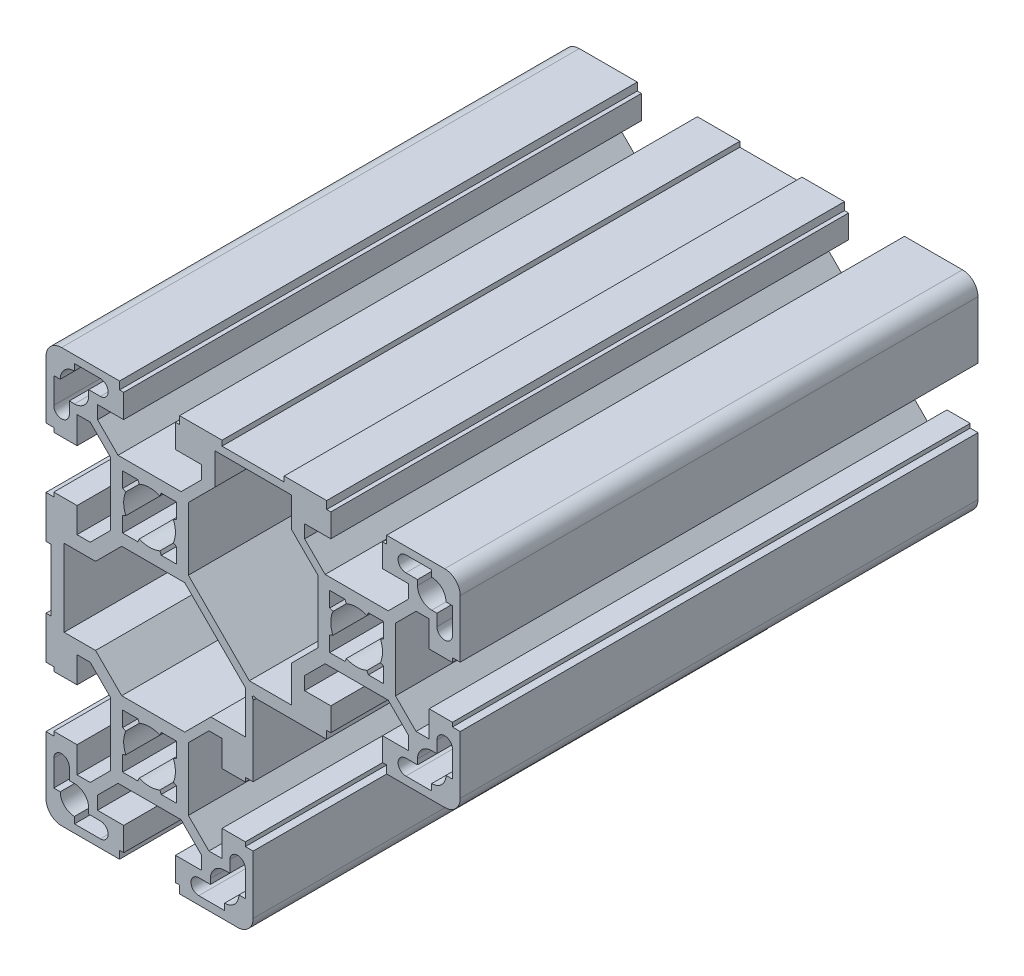
from build123d import *

# Parameters (mm, degrees)
EXTRUDE1_DEPTH = 100


with BuildPart() as part:
    # Sketch1 → Extrude1 (new body)
    with BuildSketch(Plane.XY):
        with BuildLine():
            Line((25.999948, 38.999922), (13.999972, 38.999922))
            Line((13.999972, 38.999922), (13.999972, 39.99992))
            Line((13.999972, 39.99992), (5.7999884, 39.99992))
            Line((5.7999884, 39.99992), (5.7999884, 38.499923))
            Line((5.7999884, 38.499923), (5, 38.499923))
            Line((5, 38.499923), (5, 33.931528137))
            Line((5, 33.931528137), (10.0499799, 33.931528137))
            Line((10.0499799, 33.931528137), (10.0499799, 31.395747208))
            Line((10.0499799, 31.395747208), (6.085773828, 27.431541137))
            Line((6.085773828, 27.431541137), (-6.085773828, 27.431541137))
            Line((-6.085773828, 27.431541137), (-10.0499799, 31.395747208))
            Line((-10.0499799, 31.395747208), (-10.0499799, 33.931528137))
            Line((-10.0499799, 33.931528137), (-5, 33.931528137))
            Line((-5, 33.931528137), (-5, 38.499923))
            Line((-5, 38.499923), (-5.7999884, 38.499923))
            Line((-5.7999884, 38.499923), (-5.7999884, 39.99992))
            Line((-5.7999884, 39.99992), (-16.999966, 39.99992))
            ThreePointArc((-16.999966, 39.99992), (-19.121282101, 39.121242101), (-19.99996, 36.999926))
            Line((-19.99996, 36.999926), (-19.99996, 25.868352263))
            Line((-19.99996, 25.868352263), (-18.499963, 25.868352263))
            Line((-18.499963, 25.868352263), (-18.499963, 25.068373863))
            Line((-18.499963, 25.068373863), (-13.999972, 25.068373863))
            Line((-13.999972, 25.068373863), (-13.999972, 30.29511991))
            Line((-13.999972, 30.29511991), (-11.464191072, 30.29511991))
            Line((-11.464191072, 30.29511991), (-7.499985, 26.330913838))
            Line((-7.499985, 26.330913838), (-7.499985, 14.159366181))
            Line((-7.499985, 14.159366181), (-11.464191072, 10.19516011))
            Line((-11.464191072, 10.19516011), (-13.999972, 10.19516011))
            Line((-13.999972, 10.19516011), (-13.999972, 15.068373863))
            Line((-13.999972, 15.068373863), (-18.499963, 15.068373863))
            Line((-18.499963, 15.068373863), (-18.499963, 14.268375463))
            Line((-18.499963, 14.268375463), (-19.99996, 14.268375463))
            Line((-19.99996, 14.268375463), (-19.99996, 6.068391863))
            Line((-19.99996, 6.068391863), (-18.999962, 6.068391863))
            Line((-18.999962, 6.068391863), (-18.999962, -5.931584137))
            Line((-18.999962, -5.931584137), (-19.99996, -5.931584137))
            Line((-19.99996, -5.931584137), (-19.99996, -14.131567737))
            Line((-19.99996, -14.131567737), (-18.499963, -14.131567737))
            Line((-18.499963, -14.131567737), (-18.499963, -14.931546137))
            Line((-18.499963, -14.931546137), (-13.999972, -14.931546137))
            Line((-13.999972, -14.931546137), (-13.999972, -9.881576237))
            Line((-13.999972, -9.881576237), (-11.464191072, -9.881576237))
            Line((-11.464191072, -9.881576237), (-7.499985, -13.845782308))
            Line((-7.499985, -13.845782308), (-7.499985, -26.017329965))
            Line((-7.499985, -26.017329965), (-11.464191072, -29.981536037))
            Line((-11.464191072, -29.981536037), (-13.999972, -29.981536037))
            Line((-13.999972, -29.981536037), (-13.999972, -24.931546137))
            Line((-13.999972, -24.931546137), (-18.499963, -24.931546137))
            Line((-18.499963, -24.931546137), (-18.499963, -25.731544537))
            Line((-18.499963, -25.731544537), (-19.99996, -25.731544537))
            Line((-19.99996, -25.731544537), (-19.99996, -36.999926))
            ThreePointArc((-19.99996, -36.999926), (-19.121282101, -39.121242101), (-16.999966, -39.99992))
            Line((-16.999966, -39.99992), (-5.7999884, -39.99992))
            Line((-5.7999884, -39.99992), (-5.7999884, -38.499923))
            Line((-5.7999884, -38.499923), (-5, -38.499923))
            Line((-5, -38.499923), (-5, -33.931528137))
            Line((-5, -33.931528137), (-10.0499799, -33.931528137))
            Line((-10.0499799, -33.931528137), (-10.0499799, -31.395747208))
            Line((-10.0499799, -31.395747208), (-6.085773828, -27.431541137))
            Line((-6.085773828, -27.431541137), (6.085773828, -27.431541137))
            Line((6.085773828, -27.431541137), (10.0499799, -31.395747208))
            Line((10.0499799, -31.395747208), (10.0499799, -33.931528137))
            Line((10.0499799, -33.931528137), (5, -33.931528137))
            Line((5, -33.931528137), (5, -38.499923))
            Line((5, -38.499923), (5.7999884, -38.499923))
            Line((5.7999884, -38.499923), (5.7999884, -39.99992))
            Line((5.7999884, -39.99992), (16.999966, -39.99992))
            ThreePointArc((16.999966, -39.99992), (19.121282101, -39.121242101), (19.99996, -36.999926))
            Line((19.99996, -36.999926), (19.99996, -25.731544537))
            Line((19.99996, -25.731544537), (18.499963, -25.731544537))
            Line((18.499963, -25.731544537), (18.499963, -24.931546137))
            Line((18.499963, -24.931546137), (13.999972, -24.931546137))
            Line((13.999972, -24.931546137), (13.999972, -29.981536037))
            Line((13.999972, -29.981536037), (11.464191072, -29.981536037))
            Line((11.464191072, -29.981536037), (7.499985, -26.017329965))
            Line((7.499985, -26.017329965), (7.499985, -13.845782308))
            Line((7.499985, -13.845782308), (11.464191072, -9.881576237))
            Line((11.464191072, -9.881576237), (13.999972, -9.881576237))
            Line((13.999972, -9.881576237), (13.999972, -14.931566137))
            Line((13.999972, -14.931566137), (18.499963, -14.931566137))
            Line((18.499963, -14.931566137), (18.499963, -14.131567737))
            Line((18.499963, -14.131567737), (19.99996, -14.131567737))
            Line((19.99996, -14.131567737), (19.99996, -0.516355967))
            Line((19.99996, -0.516355967), (19.812021376, 0))
            Line((19.812021376, 0), (20.068363863, 0.256342487))
            Line((20.068363863, 0.256342487), (20.58471983, 0.068403863))
            Line((20.58471983, 0.068403863), (34.1999316, 0.068403863))
            Line((34.1999316, 0.068403863), (34.1999316, 1.568400863))
            Line((34.1999316, 1.568400863), (34.99993, 1.568400863))
            Line((34.99993, 1.568400863), (34.99993, 6.068391863))
            Line((34.99993, 6.068391863), (29.9499401, 6.068391863))
            Line((29.9499401, 6.068391863), (29.9499401, 8.604172792))
            Line((29.9499401, 8.604172792), (33.914146172, 12.568378863))
            Line((33.914146172, 12.568378863), (46.085693828, 12.568378863))
            Line((46.085693828, 12.568378863), (50.0498999, 8.604172792))
            Line((50.0498999, 8.604172792), (50.0498999, 6.068391863))
            Line((50.0498999, 6.068391863), (44.99993, 6.068391863))
            Line((44.99993, 6.068391863), (44.99993, 1.568400863))
            Line((44.99993, 1.568400863), (45.7999084, 1.568400863))
            Line((45.7999084, 1.568400863), (45.7999084, 0.068403863))
            Line((45.7999084, 0.068403863), (56.999886, 0.068403863))
            ThreePointArc((56.999886, 0.068403863), (59.121202101, 0.947081762), (59.99988, 3.068397863))
            Line((59.99988, 3.068397863), (59.99988, 14.268375463))
            Line((59.99988, 14.268375463), (58.499883, 14.268375463))
            Line((58.499883, 14.268375463), (58.499883, 15.068373863))
            Line((58.499883, 15.068373863), (53.999892, 15.068373863))
            Line((53.999892, 15.068373863), (53.999892, 10.018383963))
            Line((53.999892, 10.018383963), (51.464111072, 10.018383963))
            Line((51.464111072, 10.018383963), (47.499905, 13.982590035))
            Line((47.499905, 13.982590035), (47.499905, 26.154137692))
            Line((47.499905, 26.154137692), (51.464111072, 30.118343763))
            Line((51.464111072, 30.118343763), (53.999892, 30.118343763))
            Line((53.999892, 30.118343763), (53.999892, 25.068353863))
            Line((53.999892, 25.068353863), (58.499883, 25.068353863))
            Line((58.499883, 25.068353863), (58.499883, 25.868352263))
            Line((58.499883, 25.868352263), (59.99988, 25.868352263))
            Line((59.99988, 25.868352263), (59.99988, 36.999926))
            ThreePointArc((59.99988, 36.999926), (59.121202101, 39.121242101), (56.999886, 39.99992))
            Line((56.999886, 39.99992), (45.7999284, 39.99992))
            Line((45.7999284, 39.99992), (45.7999284, 38.499923))
            Line((45.7999284, 38.499923), (44.99993, 38.499923))
            Line((44.99993, 38.499923), (44.99993, 33.999932))
            Line((44.99993, 33.999932), (50.0498999, 33.999932))
            Line((50.0498999, 33.999932), (50.0498999, 31.464151072))
            Line((50.0498999, 31.464151072), (46.085693828, 27.499945))
            Line((46.085693828, 27.499945), (33.914146172, 27.499945))
            Line((33.914146172, 27.499945), (29.9499401, 31.464151072))
            Line((29.9499401, 31.464151072), (29.9499401, 33.999932))
            Line((29.9499401, 33.999932), (34.99993, 33.999932))
            Line((34.99993, 33.999932), (34.99993, 38.499923))
            Line((34.99993, 38.499923), (34.1999316, 38.499923))
            Line((34.1999316, 38.499923), (34.1999316, 39.99992))
            Line((34.1999316, 39.99992), (25.999948, 39.99992))
            Line((25.999948, 39.99992), (25.999948, 38.999922))
        make_face()
        Polygon((27.4499451, 2.391622717), (19.267728464, 2.391622717), (7.499985, 14.159366181), (7.499985, 26.330913838), (12.638362973, 31.469291811), (12.638362973, 37.540599669), (27.4499451, 37.540599669), (27.4499451, 31.734456031), (32.499935, 26.684466131), (32.499935, 14.512918474), (27.4499451, 9.462928574), align=None, mode=Mode.SUBTRACT)
        with BuildLine():
            Line((57.2498855, 34.568334863), (58.499883, 34.568334863))
            Line((58.499883, 34.568334863), (58.499883, 29.568344863))
            ThreePointArc((58.499883, 29.568344863), (56.999886, 28.068347863), (55.499889, 29.568344863))
            Line((55.499889, 29.568344863), (55.499889, 31.818340363))
            Line((55.499889, 31.818340363), (54.499891, 31.818340363))
            ThreePointArc((54.499891, 31.818340363), (52.555351241, 32.623795104), (51.7498965, 34.568334863))
            Line((51.7498965, 34.568334863), (51.7498965, 35.568332863))
            Line((51.7498965, 35.568332863), (49.499901, 35.568332863))
            ThreePointArc((49.499901, 35.568332863), (47.999904, 37.068329863), (49.499901, 38.568326863))
            Line((49.499901, 38.568326863), (54.499891, 38.568326863))
            Line((54.499891, 38.568326863), (54.499891, 37.318329363))
            ThreePointArc((54.499891, 37.318329363), (56.444430759, 36.512874622), (57.2498855, 34.568334863))
        make_face(mode=Mode.SUBTRACT)
        with BuildLine():
            Line((58.499883, 5.568392863), (57.2498855, 5.568392863))
            ThreePointArc((57.2498855, 5.568392863), (56.444430759, 3.623853104), (54.499891, 2.818398363))
            Line((54.499891, 2.818398363), (54.499891, 1.568400863))
            Line((54.499891, 1.568400863), (49.499901, 1.568400863))
            ThreePointArc((49.499901, 1.568400863), (47.999904, 3.068397863), (49.499901, 4.568394863))
            Line((49.499901, 4.568394863), (51.7498965, 4.568394863))
            Line((51.7498965, 4.568394863), (51.7498965, 5.568392863))
            ThreePointArc((51.7498965, 5.568392863), (52.555351241, 7.512932622), (54.499891, 8.318387363))
            Line((54.499891, 8.318387363), (55.499889, 8.318387363))
            Line((55.499889, 8.318387363), (55.499889, 10.568382863))
            ThreePointArc((55.499889, 10.568382863), (56.999886, 12.068379863), (58.499883, 10.568382863))
            Line((58.499883, 10.568382863), (58.499883, 5.568392863))
        make_face(mode=Mode.SUBTRACT)
        with BuildLine():
            Line((41.993114909, 24.653892628), (42.260203479, 25.268353463))
            Line((42.260203479, 25.268353463), (45.1999096, 25.268353463))
            Line((45.1999096, 25.268353463), (45.1999096, 22.328647343))
            Line((45.1999096, 22.328647343), (44.585448765, 22.061558772))
            ThreePointArc((44.585448765, 22.061558772), (44.99991, 20.068363863), (44.585448765, 18.075168954))
            Line((44.585448765, 18.075168954), (45.1999096, 17.808080384))
            Line((45.1999096, 17.808080384), (45.1999096, 14.868374263))
            Line((45.1999096, 14.868374263), (42.260203479, 14.868374263))
            Line((42.260203479, 14.868374263), (41.993114909, 15.482835098))
            ThreePointArc((41.993114909, 15.482835098), (39.99992, 15.068373863), (38.006725091, 15.482835098))
            Line((38.006725091, 15.482835098), (37.739636521, 14.868374263))
            Line((37.739636521, 14.868374263), (34.7999304, 14.868374263))
            Line((34.7999304, 14.868374263), (34.7999304, 17.808080384))
            Line((34.7999304, 17.808080384), (35.414391235, 18.075168954))
            ThreePointArc((35.414391235, 18.075168954), (34.99993, 20.068363863), (35.414391235, 22.061558772))
            Line((35.414391235, 22.061558772), (34.7999304, 22.328647343))
            Line((34.7999304, 22.328647343), (34.7999304, 25.268353463))
            Line((34.7999304, 25.268353463), (37.739636521, 25.268353463))
            Line((37.739636521, 25.268353463), (38.006725091, 24.653892628))
            ThreePointArc((38.006725091, 24.653892628), (39.99992, 25.068353863), (41.993114909, 24.653892628))
        make_face(mode=Mode.SUBTRACT)
        Polygon((18.560621879, 0.800635399), (18.560621879, -7.381581237), (11.842868314, -7.381581237), (6.792878414, -12.431571137), (-5.378669243, -12.431571137), (-10.428659143, -7.381581237), (-16.499967, -7.381581237), (-16.499967, 7.518388963), (-10.428659143, 7.518388963), (-5.378669243, 12.568378863), (6.792878414, 12.568378863), align=None, mode=Mode.SUBTRACT)
        with BuildLine():
            Line((2.260283479, 25.268353463), (5.1999896, 25.268353463))
            Line((5.1999896, 25.268353463), (5.1999896, 22.328647343))
            Line((5.1999896, 22.328647343), (4.585528765, 22.061558772))
            ThreePointArc((4.585528765, 22.061558772), (4.99999, 20.068363863), (4.585528765, 18.075168954))
            Line((4.585528765, 18.075168954), (5.1999896, 17.808080384))
            Line((5.1999896, 17.808080384), (5.1999896, 14.868374263))
            Line((5.1999896, 14.868374263), (2.260283479, 14.868374263))
            Line((2.260283479, 14.868374263), (1.993194909, 15.482835098))
            ThreePointArc((1.993194909, 15.482835098), (0, 15.068373863), (-1.993194909, 15.482835098))
            Line((-1.993194909, 15.482835098), (-2.260283479, 14.868374263))
            Line((-2.260283479, 14.868374263), (-5.1999896, 14.868374263))
            Line((-5.1999896, 14.868374263), (-5.1999896, 17.808080384))
            Line((-5.1999896, 17.808080384), (-4.585528765, 18.075168954))
            ThreePointArc((-4.585528765, 18.075168954), (-4.99999, 20.068363863), (-4.585528765, 22.061558772))
            Line((-4.585528765, 22.061558772), (-5.1999896, 22.328647343))
            Line((-5.1999896, 22.328647343), (-5.1999896, 25.268353463))
            Line((-5.1999896, 25.268353463), (-2.260283479, 25.268353463))
            Line((-2.260283479, 25.268353463), (-1.993194909, 24.653892628))
            ThreePointArc((-1.993194909, 24.653892628), (0, 25.068353863), (1.993194909, 24.653892628))
            Line((1.993194909, 24.653892628), (2.260283479, 25.268353463))
        make_face(mode=Mode.SUBTRACT)
        with BuildLine():
            Line((-18.499963, 34.568334863), (-17.2499655, 34.568334863))
            ThreePointArc((-17.2499655, 34.568334863), (-16.444510759, 36.512874622), (-14.499971, 37.318329363))
            Line((-14.499971, 37.318329363), (-14.499971, 38.568326863))
            Line((-14.499971, 38.568326863), (-9.499981, 38.568326863))
            ThreePointArc((-9.499981, 38.568326863), (-7.999984, 37.068329863), (-9.499981, 35.568332863))
            Line((-9.499981, 35.568332863), (-11.7499765, 35.568332863))
            Line((-11.7499765, 35.568332863), (-11.7499765, 34.568334863))
            ThreePointArc((-11.7499765, 34.568334863), (-12.555431241, 32.623795104), (-14.499971, 31.818340363))
            Line((-14.499971, 31.818340363), (-15.499969, 31.818340363))
            Line((-15.499969, 31.818340363), (-15.499969, 29.568344863))
            ThreePointArc((-15.499969, 29.568344863), (-16.999966, 28.068347863), (-18.499963, 29.568344863))
            Line((-18.499963, 29.568344863), (-18.499963, 34.568334863))
        make_face(mode=Mode.SUBTRACT)
        with BuildLine():
            Line((2.260283479, -14.731566537), (5.1999896, -14.731566537))
            Line((5.1999896, -14.731566537), (5.1999896, -17.671272657))
            Line((5.1999896, -17.671272657), (4.585528765, -17.938361228))
            ThreePointArc((4.585528765, -17.938361228), (4.99999, -19.931556137), (4.585528765, -21.924751046))
            Line((4.585528765, -21.924751046), (5.1999896, -22.191839616))
            Line((5.1999896, -22.191839616), (5.1999896, -25.131545737))
            Line((5.1999896, -25.131545737), (2.260283479, -25.131545737))
            Line((2.260283479, -25.131545737), (1.993194909, -24.517084902))
            ThreePointArc((1.993194909, -24.517084902), (0, -24.931546137), (-1.993194909, -24.517084902))
            Line((-1.993194909, -24.517084902), (-2.260283479, -25.131545737))
            Line((-2.260283479, -25.131545737), (-5.1999896, -25.131545737))
            Line((-5.1999896, -25.131545737), (-5.1999896, -22.191839616))
            Line((-5.1999896, -22.191839616), (-4.585528765, -21.924751046))
            ThreePointArc((-4.585528765, -21.924751046), (-4.99999, -19.931556137), (-4.585528765, -17.938361228))
            Line((-4.585528765, -17.938361228), (-5.1999896, -17.671272657))
            Line((-5.1999896, -17.671272657), (-5.1999896, -14.731566537))
            Line((-5.1999896, -14.731566537), (-2.260283479, -14.731566537))
            Line((-2.260283479, -14.731566537), (-1.993194909, -15.346027372))
            ThreePointArc((-1.993194909, -15.346027372), (0, -14.931566137), (1.993194909, -15.346027372))
            Line((1.993194909, -15.346027372), (2.260283479, -14.731566537))
        make_face(mode=Mode.SUBTRACT)
        with BuildLine():
            Line((14.499971, -37.181521637), (14.499971, -38.431519137))
            Line((14.499971, -38.431519137), (9.499981, -38.431519137))
            ThreePointArc((9.499981, -38.431519137), (7.999984, -36.931522137), (9.499981, -35.431525137))
            Line((9.499981, -35.431525137), (11.7499765, -35.431525137))
            Line((11.7499765, -35.431525137), (11.7499765, -34.431527137))
            ThreePointArc((11.7499765, -34.431527137), (12.555431241, -32.486987378), (14.499971, -31.681532637))
            Line((14.499971, -31.681532637), (15.499969, -31.681532637))
            Line((15.499969, -31.681532637), (15.499969, -29.431537137))
            ThreePointArc((15.499969, -29.431537137), (16.999966, -27.931540137), (18.499963, -29.431537137))
            Line((18.499963, -29.431537137), (18.499963, -34.431527137))
            Line((18.499963, -34.431527137), (17.2499655, -34.431527137))
            ThreePointArc((17.2499655, -34.431527137), (16.444510759, -36.376066896), (14.499971, -37.181521637))
        make_face(mode=Mode.SUBTRACT)
        with BuildLine():
            Line((-17.2499655, -34.431527137), (-18.499963, -34.431527137))
            Line((-18.499963, -34.431527137), (-18.499963, -29.431537137))
            ThreePointArc((-18.499963, -29.431537137), (-16.999966, -27.931540137), (-15.499969, -29.431537137))
            Line((-15.499969, -29.431537137), (-15.499969, -31.681532637))
            Line((-15.499969, -31.681532637), (-14.499971, -31.681532637))
            ThreePointArc((-14.499971, -31.681532637), (-12.555431241, -32.486987378), (-11.7499765, -34.431527137))
            Line((-11.7499765, -34.431527137), (-11.7499765, -35.431525137))
            Line((-11.7499765, -35.431525137), (-9.499981, -35.431525137))
            ThreePointArc((-9.499981, -35.431525137), (-7.999984, -36.931522137), (-9.499981, -38.431519137))
            Line((-9.499981, -38.431519137), (-14.499971, -38.431519137))
            Line((-14.499971, -38.431519137), (-14.499971, -37.181521637))
            ThreePointArc((-14.499971, -37.181521637), (-16.444510759, -36.376066896), (-17.2499655, -34.431527137))
        make_face(mode=Mode.SUBTRACT)
    extrude(amount=-EXTRUDE1_DEPTH)


solid = part.part
